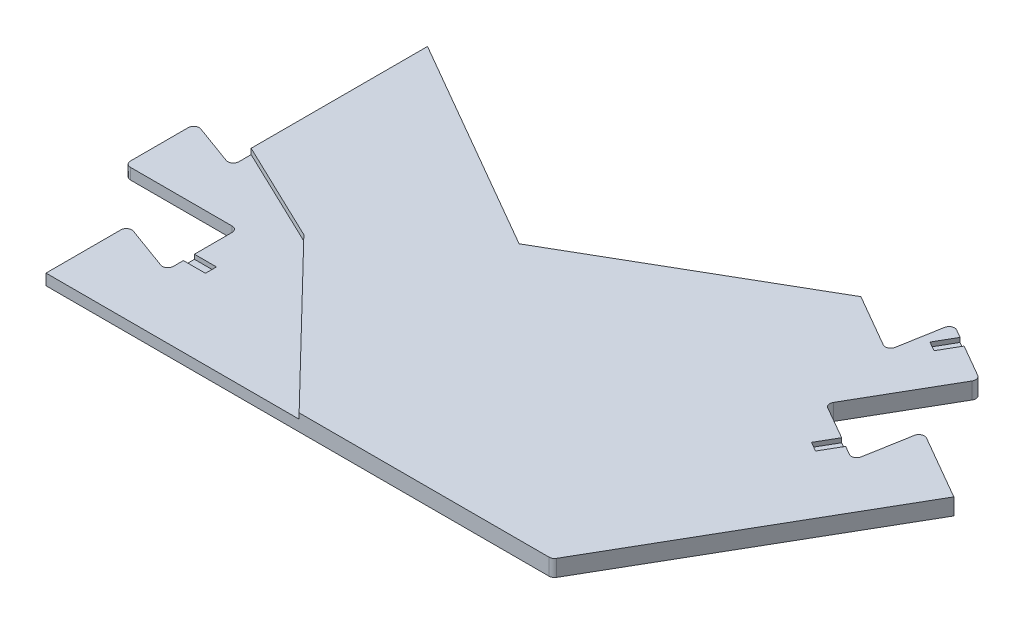
from build123d import *

# Parameters (mm, degrees)
P_IDAT_VYSUNUT_M1_DEPTH  = 3
P_IDAT_VYSUNUT_M2_DEPTH  = 2
ZAOBLIT1_R               = 1
SKICA3_W                 = 4
SKICA3_H                 = 2
ODEBRAT_VYSUNUT_M1_DEPTH = 0.8
ODEBRAT_VYSUNUT_M2_DEPTH = 0.8


with BuildPart() as part:
    # Skica1 → P_idat vysunut_m1 (new body)
    with BuildSketch(Plane(origin=(0, 0, 0), x_dir=(1, 0, 0), z_dir=(0, 1, 0))):
        Polygon((26.667853432, 46.190077074), (13.677472376, 53.690077074), (11.737150801, 42.685966604), (0.392218012, 49.235966604), (10.61747027, 66.946623035), (-0.554257439, 73.396623035), (-2.393036353, 62.968389614), (-13.22114317, 69.22), (-52.538696502, 46.52), (-91.856249834, 69.22), (-91.856249834, 37.22), (-73.49138407, 28.419769911), (-45.928124917, 0), (0, 0), align=None)
    extrude(amount=P_IDAT_VYSUNUT_M1_DEPTH)

    # Skica1_15 → P_idat vysunut_m2 (add)
    with BuildSketch(Plane(origin=(0, 0, 0), x_dir=(1, 0, 0), z_dir=(0, 1, 0))):
        Polygon((-91.856249834, 0), (-45.928124917, 0), (-73.49138407, 28.419769911), (-91.856249834, 37.22), (-91.856249834, 33.55662508), (-101.80675435, 37.17831254), (-101.80675435, 24.27831254), (-81.356249834, 24.27831254), (-81.356249834, 11.17831254), (-91.856249834, 15), align=None)
    extrude(amount=P_IDAT_VYSUNUT_M2_DEPTH)

    # Zaoblit1
    zaoblit1_edges = [part.edges().sort_by_distance(p)[0] for p in [
        (-81.356249834, 1, -11.17831254),
        (-91.856249834, 1, -15),
        (-81.356249834, 1, -24.27831254),
        (-101.80675435, 1, -24.27831254),
        (-101.80675435, 1, -37.17831254),
        (-91.856249834, 1, -33.55662508),
        (0, 1.5, 0),
        (13.677472376, 1.5, -53.690077074),
        (11.737150801, 1.5, -42.685966604),
        (0.392218012, 1.5, -49.235966604),
        (-2.393036353, 1.5, -62.968389614),
        (-0.554257439, 1.5, -73.396623035),
        (10.61747027, 1.5, -66.946623035),
    ]]
    fillet(zaoblit1_edges, radius=ZAOBLIT1_R)

    # Skica3 → Odebrat vysunut_m1 (cut)
    with BuildSketch(Plane(origin=(0, 2, 0), x_dir=(1, 0, 0), z_dir=(0, 1, 0))):
        with Locations((-79.356249834, 15.42831254)):
            Rectangle(SKICA3_W, SKICA3_H)
    extrude(amount=-ODEBRAT_VYSUNUT_M1_DEPTH, mode=Mode.SUBTRACT)

    # Skica4 → Odebrat vysunut_m2 (cut)
    with BuildSketch(Plane(origin=(0, 3, 0), x_dir=(1, 0, 0), z_dir=(0, 1, 0))):
        Polygon((7.190517431, 45.310966604), (5.190517431, 41.846864989), (6.922568239, 40.846864989), (8.922568239, 44.310966604), align=None)
        Polygon((0.173722583, 68.35752142), (2.173722583, 71.821623035), (3.90577339, 70.821623035), (1.90577339, 67.35752142), align=None)
    extrude(amount=-ODEBRAT_VYSUNUT_M2_DEPTH, mode=Mode.SUBTRACT)


solid = part.part
